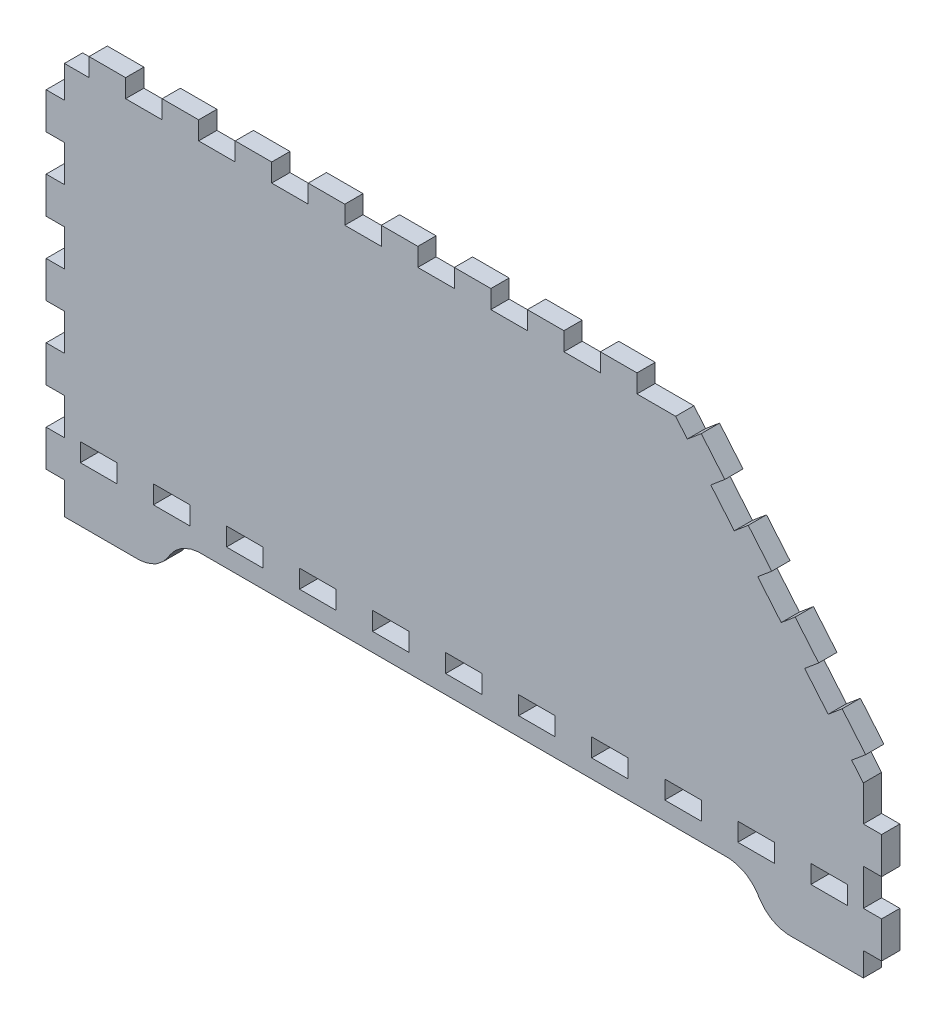
from build123d import *

# Parameters (mm, degrees)
BOSS_EXTRUDE1_DEPTH = 5.715


with BuildPart() as part:
    # Model → Boss-Extrude1 (new body)
    with BuildSketch(Plane.XY):
        Polygon((16.114776, 23.2006394), (38.974776, 23.2006394), (39.713662, 23.2006394), (41.932098, 23.590631), (44.254166, 24.4808502), (44.689776, 24.7316498), (45.123862, 24.983821), (47.05604, 26.54935), (48.622712, 28.481274), (48.87341, 28.91536), (49.124362, 29.350716), (50.690018, 31.282894), (52.621688, 32.848296), (53.057044, 33.098994), (53.491384, 33.349946), (55.813198, 34.241486), (58.031888, 34.630106), (58.772044, 34.630106), (223.458532, 34.630106), (224.197418, 34.630106), (226.415854, 34.241486), (228.737922, 33.349946), (229.173278, 33.098994), (229.60711, 32.848296), (231.539288, 31.282894), (233.104944, 29.350716), (233.355388, 28.91536), (233.60634, 28.481274), (235.171996, 26.54935), (237.103666, 24.983821), (237.539276, 24.7316498), (237.973362, 24.4808502), (240.2967, 23.590631), (242.51539, 23.2006394), (243.255546, 23.2006394), (266.11326, 23.2006394), (266.11326, 30.64891), (271.8308, 30.64891), (271.8308, 42.078402), (266.11326, 42.078402), (266.11326, 53.509418), (271.8308, 53.509418), (271.8308, 64.938656), (266.11326, 64.938656), (266.11326, 76.060554), (262.46074, 80.41386), (266.8397, 84.087716), (259.49148, 92.844112), (255.11252, 89.170256), (247.767094, 97.926144), (252.145038, 101.6), (244.797326, 110.355888), (240.419382, 106.682032), (233.073194, 115.438428), (237.451138, 119.112284), (230.103426, 127.868172), (225.725482, 124.194316), (218.37904, 132.950204), (222.757238, 136.62406), (215.409272, 145.378932), (211.031328, 141.7066), (207.3783, 146.060922), (195.283328, 146.060922), (195.283328, 151.775668), (183.852312, 151.775668), (183.852312, 146.060922), (172.423074, 146.060922), (172.423074, 151.775668), (160.993328, 151.775668), (160.993328, 146.060922), (149.562566, 146.060922), (149.562566, 151.775668), (138.133328, 151.775668), (138.133328, 146.060922), (126.702312, 146.060922), (126.702312, 151.775668), (115.273074, 151.775668), (115.273074, 146.060922), (103.843328, 146.060922), (103.843328, 151.775668), (92.412566, 151.775668), (92.412566, 146.060922), (80.983328, 146.060922), (80.983328, 151.775668), (69.552312, 151.775668), (69.552312, 146.060922), (58.123074, 146.060922), (58.123074, 151.775668), (46.693328, 151.775668), (46.693328, 146.060922), (35.262566, 146.060922), (35.262566, 151.775668), (23.8331756, 151.775668), (23.8331756, 146.060922), (16.114776, 146.060922), (16.114776, 136.066022), (10.4000554, 136.066022), (10.4000554, 124.63526), (16.114776, 124.63526), (16.114776, 113.205768), (10.4000554, 113.205768), (10.4000554, 101.775006), (16.114776, 101.775006), (16.114776, 90.345768), (10.4000554, 90.345768), (10.4000554, 78.916022), (16.114776, 78.916022), (16.114776, 67.48526), (10.4000554, 67.48526), (10.4000554, 56.055768), (16.114776, 56.055768), (16.114776, 44.625006), (10.4000554, 44.625006), (10.4000554, 33.195514), (16.114776, 33.195514), align=None)
        Polygon((26.815288, 40.346122), (21.1005166, 40.346122), (21.1005166, 46.060868), (32.530034, 46.060868), (32.530034, 40.346122), align=None, mode=Mode.SUBTRACT)
        Polygon((49.675796, 40.346122), (43.959272, 40.346122), (43.959272, 46.060868), (55.390288, 46.060868), (55.390288, 40.346122), align=None, mode=Mode.SUBTRACT)
        Polygon((72.534272, 40.346122), (66.819526, 40.346122), (66.819526, 46.060868), (78.250796, 46.060868), (78.250796, 40.346122), align=None, mode=Mode.SUBTRACT)
        Polygon((95.394526, 40.346122), (89.680034, 40.346122), (89.680034, 46.060868), (101.109272, 46.060868), (101.109272, 40.346122), align=None, mode=Mode.SUBTRACT)
        Polygon((118.255034, 40.346122), (112.540288, 40.346122), (112.540288, 46.060868), (123.969526, 46.060868), (123.969526, 40.346122), align=None, mode=Mode.SUBTRACT)
        Polygon((141.115288, 40.346122), (135.400796, 40.346122), (135.400796, 46.060868), (146.830034, 46.060868), (146.830034, 40.346122), align=None, mode=Mode.SUBTRACT)
        Polygon((163.975796, 40.346122), (158.259272, 40.346122), (158.259272, 46.060868), (169.690288, 46.060868), (169.690288, 40.346122), align=None, mode=Mode.SUBTRACT)
        Polygon((186.834272, 40.346122), (181.119526, 40.346122), (181.119526, 46.060868), (192.550796, 46.060868), (192.550796, 40.346122), align=None, mode=Mode.SUBTRACT)
        Polygon((209.694526, 40.346122), (203.980034, 40.346122), (203.980034, 46.060868), (215.409272, 46.060868), (215.409272, 40.346122), align=None, mode=Mode.SUBTRACT)
        Polygon((232.555034, 40.346122), (226.840288, 40.346122), (226.840288, 46.060868), (238.269526, 46.060868), (238.269526, 40.346122), align=None, mode=Mode.SUBTRACT)
        Polygon((255.41478, 40.346122), (249.700796, 40.346122), (249.700796, 46.060868), (261.12978, 46.060868), (261.12978, 40.346122), align=None, mode=Mode.SUBTRACT)
    extrude(amount=BOSS_EXTRUDE1_DEPTH)


solid = part.part
